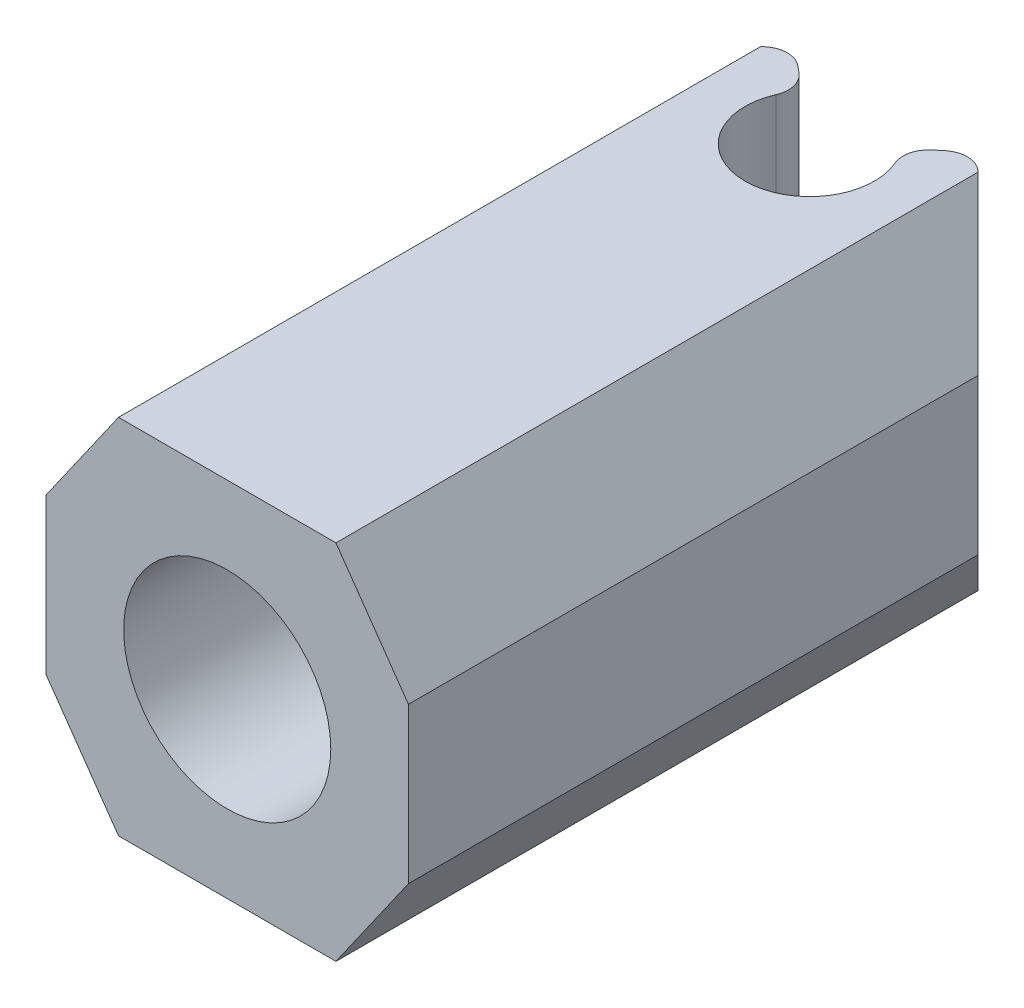
from build123d import *

# Parameters (mm, degrees)
SKETCH1_W               = 14
SKETCH1_H               = 15
BOSS_EXTRUDE1_DEPTH     = 7
SKETCH3_R               = 4
CUT_EXTRUDE1_DEPTH      = 16
SKETCH4_W               = 14
SKETCH4_H               = 14
BOSS_EXTRUDE2_DEPTH     = 12
SKETCH7_R               = 6
CUT_EXTRUDE7_DEPTH      = 3
SKETCH8_R               = 2.5
CUT_EXTRUDE8_DEPTH      = 11
CUT_EXTRUDE8_DEPTH_BACK = 5
SKETCH9_W               = 4.5
SKETCH9_H               = 6
CUT_EXTRUDE9_DEPTH      = 8
CUT_EXTRUDE9_DEPTH_BACK = 8
CHAMFER1_SIZE           = 5
SKETCH13_R              = 3.5
SKETCH13_R_2            = 2.5
BOSS_EXTRUDE3_DEPTH     = 1
CUT_EXTRUDE10_DEPTH     = 6
CHAMFER2_SIZE           = 4
CHAMFER2_SIZE2          = 2.800830153
CHAMFER2_PART_2_SIZE    = 4
CHAMFER2_PART_2_SIZE2   = 2.800830153
CHAMFER3_SIZE           = 4
CHAMFER3_SIZE2          = 2.800830153
CHAMFER3_PART_2_SIZE    = 4
CHAMFER3_PART_2_SIZE2   = 2.800830153
FILLET1_R               = 1
FILLET2_R               = 4


with BuildPart() as part:
    # Sketch1 → Boss-Extrude1 (new body, symmetric)
    with BuildSketch(Plane(origin=(0, 0, 0), x_dir=(1, 0, 0), z_dir=(0, 1, 0))):
        Rectangle(SKETCH1_W, SKETCH1_H)
    extrude(amount=BOSS_EXTRUDE1_DEPTH, both=True)

    # Sketch3 → Cut-Extrude1 (cut, through all)
    with BuildSketch(Plane.XY.offset(7.5)):
        Circle(SKETCH3_R)
    extrude(amount=-CUT_EXTRUDE1_DEPTH, mode=Mode.SUBTRACT)

    # Sketch4 → Boss-Extrude2 (add)
    with BuildSketch(Plane(origin=(0, 0, -7.5), x_dir=(-1, 0, 0), z_dir=(0, 0, -1))):
        Rectangle(SKETCH4_W, SKETCH4_H)
    extrude(amount=BOSS_EXTRUDE2_DEPTH)

    # Sketch7 → Cut-Extrude7 (cut, symmetric)
    with BuildSketch(Plane(origin=(0, 0, 0), x_dir=(1, 0, 0), z_dir=(0, 1, 0))):
        with Locations((0, 15)):
            Circle(SKETCH7_R)
    extrude(amount=CUT_EXTRUDE7_DEPTH, both=True, mode=Mode.SUBTRACT)

    # Sketch8 → Cut-Extrude8 (cut, two sides)
    with BuildSketch(Plane(origin=(0, -3, 0), x_dir=(1, 0, 0), z_dir=(0, 1, 0))) as cut_extrude8_sk:
        with Locations((0, 15)):
            Circle(SKETCH8_R)
    extrude(amount=CUT_EXTRUDE8_DEPTH, mode=Mode.SUBTRACT)
    extrude(cut_extrude8_sk.sketch, amount=-CUT_EXTRUDE8_DEPTH_BACK, mode=Mode.SUBTRACT)

    # Sketch9 → Cut-Extrude9 (cut, two sides)
    with BuildSketch(Plane(origin=(0, 0, 0), x_dir=(0, 0, -1), z_dir=(1, 0, 0))) as cut_extrude9_sk:
        with Locations((17.25, 0)):
            Rectangle(SKETCH9_W, SKETCH9_H)
    extrude(amount=CUT_EXTRUDE9_DEPTH, mode=Mode.SUBTRACT)
    extrude(cut_extrude9_sk.sketch, amount=-CUT_EXTRUDE9_DEPTH_BACK, mode=Mode.SUBTRACT)

    # Chamfer1
    chamfer1_edges = [part.edges().sort_by_distance(p)[0] for p in [
        (7, -5, -19.5),
        (-7, -5, -19.5),
    ]]
    chamfer(chamfer1_edges, length=CHAMFER1_SIZE)

    # Sketch13 → Boss-Extrude3 (add)
    with BuildSketch(Plane(origin=(0, -3, 0), x_dir=(1, 0, 0), z_dir=(0, 1, 0))):
        with Locations((0, 15)):
            Circle(SKETCH13_R)
        with Locations((0, 15)):
            Circle(SKETCH13_R_2, mode=Mode.SUBTRACT)
    extrude(amount=BOSS_EXTRUDE3_DEPTH)

    # Sketch14 → Cut-Extrude10 (cut)
    with BuildSketch(Plane(origin=(0, 7, 0), x_dir=(1, 0, 0), z_dir=(0, 1, 0))):
        Polygon((0, 15), (11.277541362, 24.462980798), (-11.751290712, 24.860503702), align=None)
    extrude(amount=-CUT_EXTRUDE10_DEPTH, mode=Mode.SUBTRACT)

    # Chamfer2
    chamfer2_edges = [part.edges().sort_by_distance(p)[0] for p in [
        (7, 7, -3.5),
    ]]
    chamfer2_side = [part.faces().sort_by_distance(p)[0] for p in [
        (7, 0, -3.5),
    ]]
    chamfer(chamfer2_edges, length=CHAMFER2_SIZE, length2=CHAMFER2_SIZE2, reference=chamfer2_side[0])

    # Chamfer2 part 2
    chamfer2_part_2_edges = [part.edges().sort_by_distance(p)[0] for p in [
        (-7, 7, -3.5),
    ]]
    chamfer2_part_2_side = [part.faces().sort_by_distance(p)[0] for p in [
        (-7, 0, -3.5),
    ]]
    chamfer(chamfer2_part_2_edges, length=CHAMFER2_PART_2_SIZE, length2=CHAMFER2_PART_2_SIZE2, reference=chamfer2_part_2_side[0])

    # Chamfer3
    chamfer3_edges = [part.edges().sort_by_distance(p)[0] for p in [
        (7, -7, -3.5),
    ]]
    chamfer3_side = [part.faces().sort_by_distance(p)[0] for p in [
        (7, -2, -3.5),
    ]]
    chamfer(chamfer3_edges, length=CHAMFER3_SIZE, length2=CHAMFER3_SIZE2, reference=chamfer3_side[0])

    # Chamfer3 part 2
    chamfer3_part_2_edges = [part.edges().sort_by_distance(p)[0] for p in [
        (-7, -7, -3.5),
    ]]
    chamfer3_part_2_side = [part.faces().sort_by_distance(p)[0] for p in [
        (-7, -2, -3.5),
    ]]
    chamfer(chamfer3_part_2_edges, length=CHAMFER3_PART_2_SIZE, length2=CHAMFER3_PART_2_SIZE2, reference=chamfer3_part_2_side[0])

    # Fillet1
    fillet1_edges = [part.edges().sort_by_distance(p)[0] for p in [
        (-3.534338156, 5, -17.965661844),
        (3.534338156, 5, -17.965661844),
        (1.915111108, 5, -16.606969024),
        (-1.915111108, 5, -16.606969024),
    ]]
    fillet(fillet1_edges, radius=FILLET1_R)

    # Fillet2
    fillet2_edges = [part.edges().sort_by_distance(p)[0] for p in [
        (-2, -5, -19.5),
        (2, -5, -19.5),
    ]]
    fillet(fillet2_edges, radius=FILLET2_R)


solid = part.part
